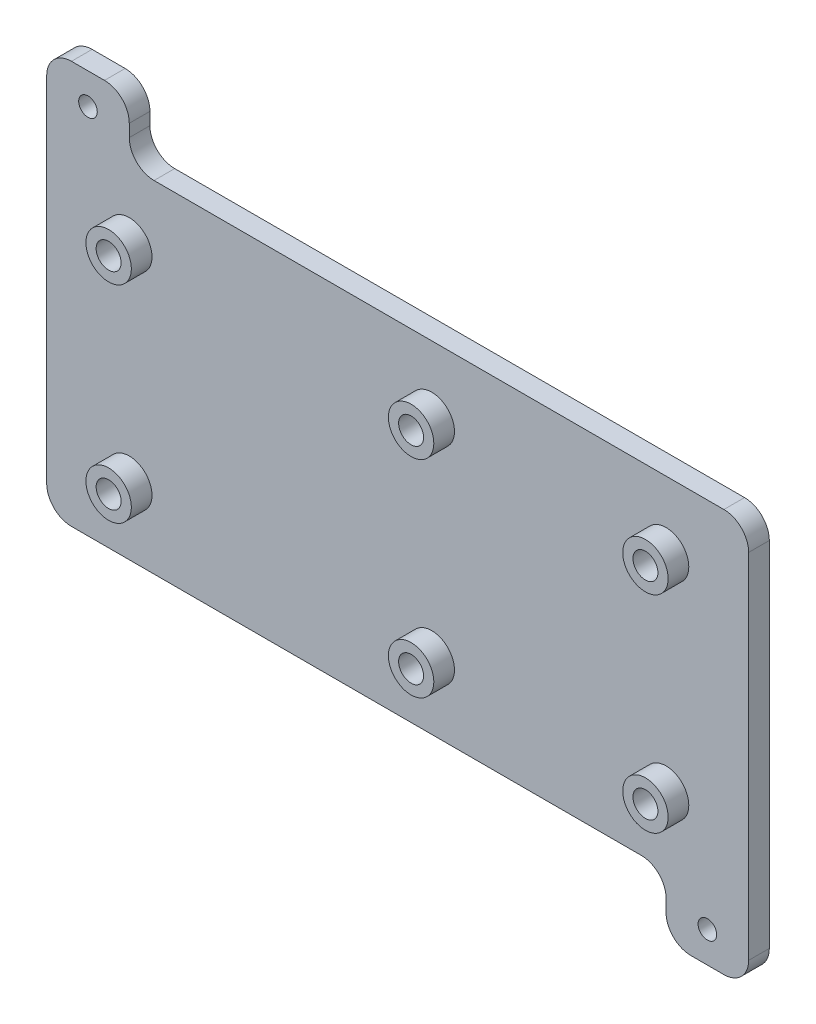
from build123d import *

# Parameters (mm, degrees)
SKETCH1_W            = 170
SKETCH1_H            = 82.55
BOSS_EXTRUDE1_DEPTH  = 5
SKETCH2_R            = 5.5
SKETCH2_R_2          = 3.025
BOSS_EXTRUDE2_DEPTH  = 5
SKETCH3_W            = 20
SKETCH3_H            = 15
BOSS_EXTRUDE3_DEPTH  = 5
FILLET1_R            = 6
M4_CLEARANCE_HOLE1_D = 4.5


with BuildPart() as part:
    # Sketch1 → Boss-Extrude1 (new body)
    with BuildSketch(Plane.XY):
        Rectangle(SKETCH1_W, SKETCH1_H)
    extrude(amount=BOSS_EXTRUDE1_DEPTH)

    # Sketch2 → Boss-Extrude2 (add)
    with BuildSketch(Plane.XY.offset(5)):
        with Locations((65, 25)):
            Circle(SKETCH2_R)
        with Locations((65, 25)):
            Circle(SKETCH2_R_2, mode=Mode.SUBTRACT)
        with Locations((8.25, 25)):
            Circle(SKETCH2_R)
        with Locations((8.25, 25)):
            Circle(SKETCH2_R_2, mode=Mode.SUBTRACT)
        with Locations((-65, 25)):
            Circle(SKETCH2_R)
        with Locations((-65, 25)):
            Circle(SKETCH2_R_2, mode=Mode.SUBTRACT)
        with Locations((-65, -25)):
            Circle(SKETCH2_R)
        with Locations((-65, -25)):
            Circle(SKETCH2_R_2, mode=Mode.SUBTRACT)
        with Locations((8.25, -25)):
            Circle(SKETCH2_R)
        with Locations((8.25, -25)):
            Circle(SKETCH2_R_2, mode=Mode.SUBTRACT)
        with Locations((65, -25)):
            Circle(SKETCH2_R)
        with Locations((65, -25)):
            Circle(SKETCH2_R_2, mode=Mode.SUBTRACT)
    extrude(amount=BOSS_EXTRUDE2_DEPTH)

    # Sketch3 → Boss-Extrude3 (add)
    with BuildSketch(Plane.XY.offset(5)):
        Polygon((-65, 56.275), (-85, 41.275), (-65, 41.275), align=None)
        Polygon((-85, 56.275), (-85, 41.275), (-65, 56.275), align=None)
        with Locations((75, -48.775)):
            Rectangle(SKETCH3_W, SKETCH3_H)
    extrude(amount=-BOSS_EXTRUDE3_DEPTH)

    # Fillet1
    fillet1_edges = [part.edges().sort_by_distance(p)[0] for p in [
        (-85, 56.275, 2.5),
        (-65, 56.275, 2.5),
        (-65, 41.275, 2.5),
        (65, -56.275, 2.5),
        (65, -41.275, 2.5),
        (85, -56.275, 2.5),
        (-85, -41.275, 2.5),
        (85, 41.275, 2.5),
    ]]
    fillet(fillet1_edges, radius=FILLET1_R)

    # M4 Clearance Hole1 (through all)
    with Locations(Plane.XY.offset(5)):
        with Locations((-75, 48.775), (75, -48.775)):
            Hole(M4_CLEARANCE_HOLE1_D / 2)


solid = part.part
